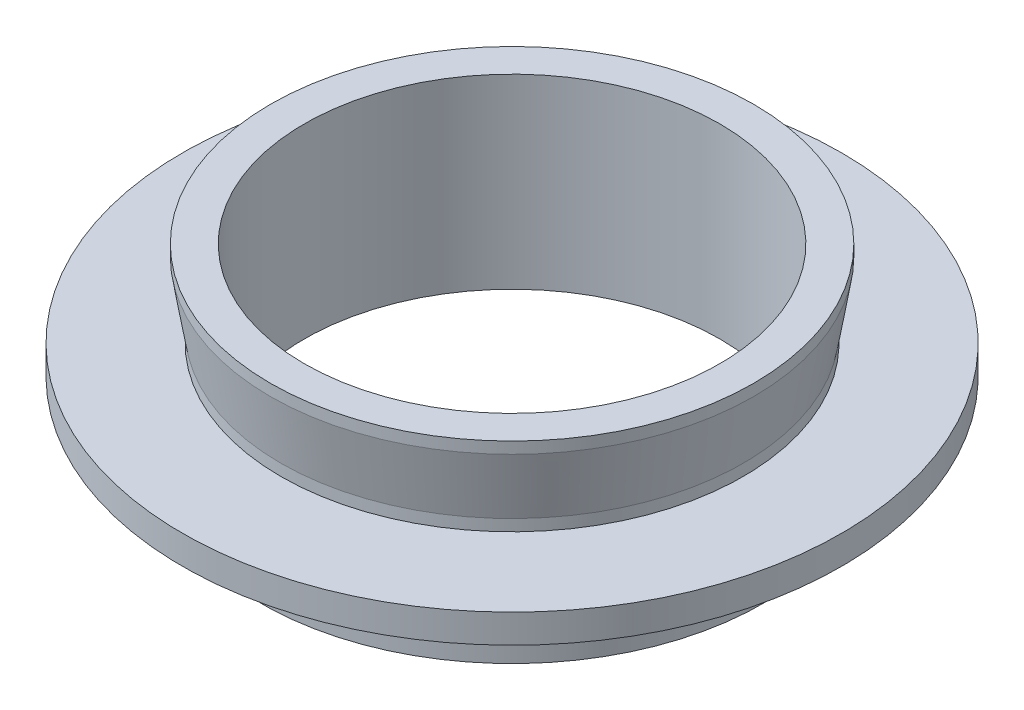
from build123d import *


with BuildPart() as part:
    # 草图1 → 旋转1 (revolve)
    with BuildSketch(Plane.XY, mode=Mode.PRIVATE) as revolve_1_sk:
        Polygon((-14.5, 0), (-14.5, 13), (-16.865, 13), (-16.865, 12.2), (-16.135, 7.8), (-16.135, 7), (-23, 7), (-23, 5), (-17.1, 5), (-17.1, 4), (-17.5, 4), (-17.5, 0), align=None)
    revolve(revolve_1_sk.sketch.rotate(Axis((0, 0, 0), (0, 1, 0)), 270), axis=Axis((0, 0, 0), (0, 1, 0)))  # turned: the seam where the file's is


solid = part.part
